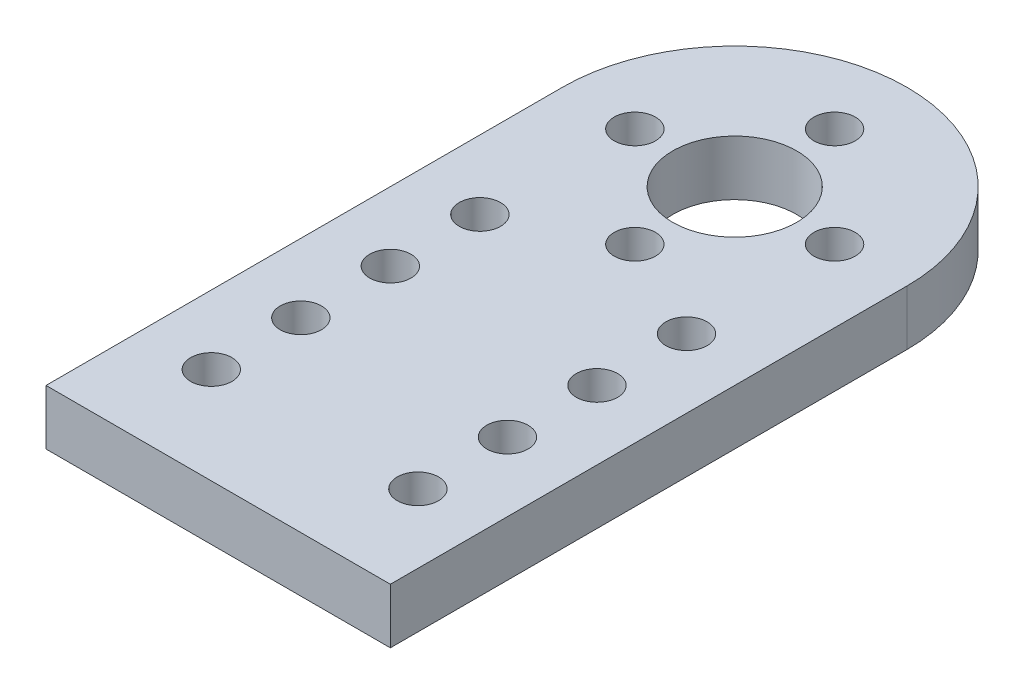
from build123d import *

# Parameters (mm, degrees)
SKETCH_1_R      = 4.5
SKETCH_1_R_2    = 1.5
EXTRUDE_1_DEPTH = 4


with BuildPart() as part:
    # Эскиз1 → Бобышка-Вытянуть1 (new body)
    with BuildSketch(Plane(origin=(0, 0, 0), x_dir=(1, 0, 0), z_dir=(0, 1, 0))):
        with BuildLine():
            Line((-12.5, 15.852233677), (-12.5, -21.647766323))
            Line((-12.5, -21.647766323), (12.5, -21.647766323))
            Line((12.5, -21.647766323), (12.5, 15.852233677))
            ThreePointArc((12.5, 15.852233677), (0, 28.352233677), (-12.5, 15.852233677))
        make_face()
        with Locations((0, 15.852233677)):
            Circle(SKETCH_1_R, mode=Mode.SUBTRACT)
        with Locations((-7.5, -14.647766323)):
            Circle(SKETCH_1_R_2, mode=Mode.SUBTRACT)
        with Locations((7.5, -14.647766323)):
            Circle(SKETCH_1_R_2, mode=Mode.SUBTRACT)
        with Locations((-7.5, -8.147766323)):
            Circle(SKETCH_1_R_2, mode=Mode.SUBTRACT)
        with Locations((7.5, -8.147766323)):
            Circle(SKETCH_1_R_2, mode=Mode.SUBTRACT)
        with Locations((-7.5, -1.647766323)):
            Circle(SKETCH_1_R_2, mode=Mode.SUBTRACT)
        with Locations((7.5, -1.647766323)):
            Circle(SKETCH_1_R_2, mode=Mode.SUBTRACT)
        with Locations((-7.5, 4.852233677)):
            Circle(SKETCH_1_R_2, mode=Mode.SUBTRACT)
        with Locations((7.5, 4.852233677)):
            Circle(SKETCH_1_R_2, mode=Mode.SUBTRACT)
        with Locations((0, 23.102233677)):
            Circle(SKETCH_1_R_2, mode=Mode.SUBTRACT)
        with Locations((7.25, 15.852233677)):
            Circle(SKETCH_1_R_2, mode=Mode.SUBTRACT)
        with Locations((0, 8.602233677)):
            Circle(SKETCH_1_R_2, mode=Mode.SUBTRACT)
        with Locations((-7.25, 15.852233677)):
            Circle(SKETCH_1_R_2, mode=Mode.SUBTRACT)
    extrude(amount=EXTRUDE_1_DEPTH)


solid = part.part
